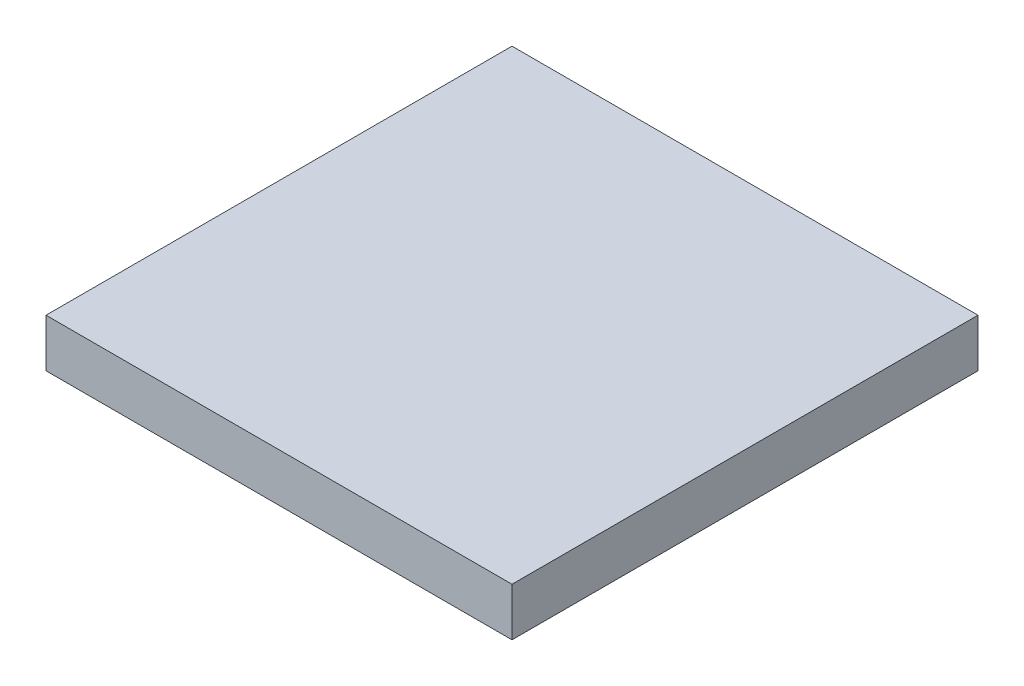
from build123d import *

# Parameters (mm, degrees)
SKETCH2_W           = 228.6
SKETCH2_H           = 228.6
BOSS_EXTRUDE1_DEPTH = 23.622


with BuildPart() as part:
    # Sketch2 → Boss-Extrude1 (new body)
    with BuildSketch(Plane(origin=(0, 0, 0), x_dir=(1, 0, 0), z_dir=(0, 1, 0))):
        Rectangle(SKETCH2_W, SKETCH2_H)
    extrude(amount=BOSS_EXTRUDE1_DEPTH)


solid = part.part
